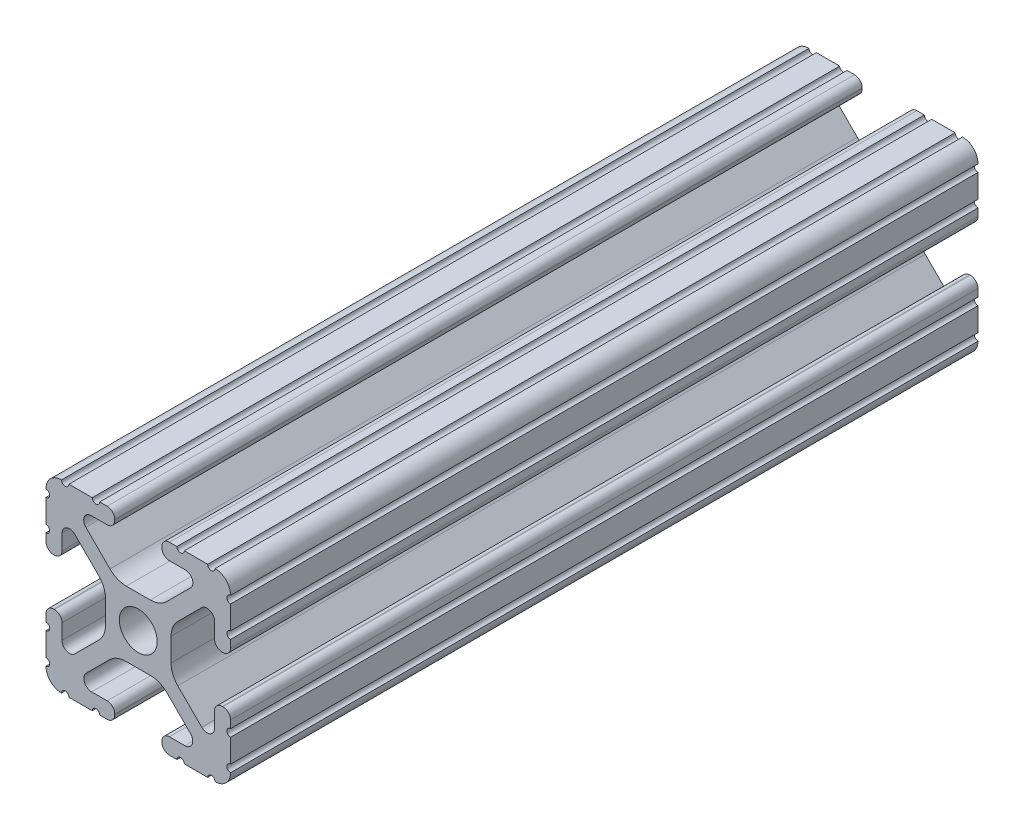
from build123d import *

# Parameters (mm, degrees)
SKETCH1_R      = 2.6035
EXTRUDE1_DEPTH = 102.87


with BuildPart() as part:
    # Sketch1 → Extrude1 (new body)
    with BuildSketch(Plane.XY):
        with BuildLine():
            Line((-1.709253557, -4.4958), (1.709253557, -4.4958))
            ThreePointArc((1.709253557, -4.4958), (2.922935876, -4.736928798), (3.95226937, -5.423689619))
            Line((3.95226937, -5.423689619), (7.179652728, -8.645192207))
            ThreePointArc((7.179652728, -8.645192207), (7.414733441, -9.822812921), (6.41641086, -10.4902))
            Line((6.41641086, -10.4902), (4.28752, -10.4902))
            ThreePointArc((4.28752, -10.4902), (3.545750844, -10.797450844), (3.2385, -11.53922))
            Line((3.2385, -11.53922), (3.2385, -11.65098))
            ThreePointArc((3.2385, -11.65098), (3.545750844, -12.392749156), (4.28752, -12.7))
            Line((4.28752, -12.7), (5.3171344, -12.7))
            ThreePointArc((5.3171344, -12.7), (5.8251344, -12.192), (6.3331344, -12.7))
            Line((6.3331344, -12.7), (9.5504, -12.7))
            ThreePointArc((9.5504, -12.7), (10.058323491, -12.192000006), (10.566399977, -12.699846982))
            ThreePointArc((10.566399977, -12.699846982), (12.082522516, -12.082522516), (12.699846982, -10.566399977))
            ThreePointArc((12.699846982, -10.566399977), (12.192000006, -10.058323491), (12.7, -9.5504))
            Line((12.7, -9.5504), (12.7, -6.3330836))
            ThreePointArc((12.7, -6.3330836), (12.192, -5.8250836), (12.7, -5.3170836))
            Line((12.7, -5.3170836), (12.7, -4.287470133))
            ThreePointArc((12.7, -4.287470133), (12.392749156, -3.545700977), (11.65098, -3.238450133))
            Line((11.65098, -3.238450133), (11.53922, -3.238450133))
            ThreePointArc((11.53922, -3.238450133), (10.797450844, -3.545700977), (10.4902, -4.287470133))
            Line((10.4902, -4.287470133), (10.4902, -6.402089023))
            ThreePointArc((10.4902, -6.402089023), (9.856394933, -7.351113629), (8.736962546, -7.129240479))
            Line((8.736962546, -7.129240479), (5.440484187, -3.838768792))
            ThreePointArc((5.440484187, -3.838768792), (4.75073678, -2.808015636), (4.5085, -1.591658411))
            Line((4.5085, -1.591658411), (4.5085, 1.591658411))
            ThreePointArc((4.5085, 1.591658411), (4.75073678, 2.808015636), (5.440484187, 3.838768792))
            Line((5.440484187, 3.838768792), (8.736962546, 7.129240479))
            ThreePointArc((8.736962546, 7.129240479), (9.856394933, 7.351113629), (10.4902, 6.402089023))
            Line((10.4902, 6.402089023), (10.4902, 4.287470133))
            ThreePointArc((10.4902, 4.287470133), (10.797450844, 3.545700977), (11.53922, 3.238450133))
            Line((11.53922, 3.238450133), (11.65098, 3.238450133))
            ThreePointArc((11.65098, 3.238450133), (12.392749156, 3.545700977), (12.7, 4.287470133))
            Line((12.7, 4.287470133), (12.7, 5.3171344))
            ThreePointArc((12.7, 5.3171344), (12.192, 5.8251344), (12.7, 6.3331344))
            Line((12.7, 6.3331344), (12.7, 9.5504))
            ThreePointArc((12.7, 9.5504), (12.192000006, 10.058323491), (12.699846982, 10.566399977))
            ThreePointArc((12.699846982, 10.566399977), (12.082522516, 12.082522516), (10.566399977, 12.699846982))
            ThreePointArc((10.566399977, 12.699846982), (10.058323491, 12.192000006), (9.5504, 12.7))
            Line((9.5504, 12.7), (6.3330836, 12.7))
            ThreePointArc((6.3330836, 12.7), (5.8250836, 12.192), (5.3170836, 12.7))
            Line((5.3170836, 12.7), (4.2874692, 12.7))
            ThreePointArc((4.2874692, 12.7), (3.545700044, 12.392749156), (3.2384492, 11.65098))
            Line((3.2384492, 11.65098), (3.2384492, 11.53922))
            ThreePointArc((3.2384492, 11.53922), (3.545700044, 10.797450844), (4.2874692, 10.4902))
            Line((4.2874692, 10.4902), (6.476774195, 10.4902))
            ThreePointArc((6.476774195, 10.4902), (7.43216212, 9.851515102), (7.207191475, 8.724540082))
            Line((7.207191475, 8.724540082), (3.900315394, 5.423689619))
            ThreePointArc((3.900315394, 5.423689619), (2.8709819, 4.736928798), (1.657299581, 4.4958))
            Line((1.657299581, 4.4958), (-1.657299581, 4.4958))
            ThreePointArc((-1.657299581, 4.4958), (-2.8709819, 4.736928798), (-3.900315394, 5.423689619))
            Line((-3.900315394, 5.423689619), (-7.207191475, 8.724540082))
            ThreePointArc((-7.207191475, 8.724540082), (-7.43216212, 9.851515102), (-6.476774195, 10.4902))
            Line((-6.476774195, 10.4902), (-4.2874692, 10.4902))
            ThreePointArc((-4.2874692, 10.4902), (-3.545700044, 10.797450844), (-3.2384492, 11.53922))
            Line((-3.2384492, 11.53922), (-3.2384492, 11.65098))
            ThreePointArc((-3.2384492, 11.65098), (-3.545700044, 12.392749156), (-4.2874692, 12.7))
            Line((-4.2874692, 12.7), (-5.3170836, 12.7))
            ThreePointArc((-5.3170836, 12.7), (-5.8250836, 12.192), (-6.3330836, 12.7))
            Line((-6.3330836, 12.7), (-9.5504, 12.7))
            ThreePointArc((-9.5504, 12.7), (-10.058323491, 12.192000006), (-10.566399977, 12.699846982))
            ThreePointArc((-10.566399977, 12.699846982), (-12.082522516, 12.082522516), (-12.699846982, 10.566399977))
            ThreePointArc((-12.699846982, 10.566399977), (-12.192000006, 10.058323491), (-12.7, 9.5504))
            Line((-12.7, 9.5504), (-12.7, 6.3331344))
            ThreePointArc((-12.7, 6.3331344), (-12.192, 5.8251344), (-12.7, 5.3171344))
            Line((-12.7, 5.3171344), (-12.7, 4.287470133))
            ThreePointArc((-12.7, 4.287470133), (-12.392749156, 3.545700977), (-11.65098, 3.238450133))
            Line((-11.65098, 3.238450133), (-11.53922, 3.238450133))
            ThreePointArc((-11.53922, 3.238450133), (-10.797450844, 3.545700977), (-10.4902, 4.287470133))
            Line((-10.4902, 4.287470133), (-10.4902, 6.402089023))
            ThreePointArc((-10.4902, 6.402089023), (-9.856394933, 7.351113629), (-8.736962546, 7.129240479))
            Line((-8.736962546, 7.129240479), (-5.440484187, 3.838768792))
            ThreePointArc((-5.440484187, 3.838768792), (-4.75073678, 2.808015636), (-4.5085, 1.591658411))
            Line((-4.5085, 1.591658411), (-4.5085, -1.591658411))
            ThreePointArc((-4.5085, -1.591658411), (-4.75073678, -2.808015636), (-5.440484187, -3.838768792))
            Line((-5.440484187, -3.838768792), (-8.736962546, -7.129240479))
            ThreePointArc((-8.736962546, -7.129240479), (-9.856394933, -7.351113629), (-10.4902, -6.402089023))
            Line((-10.4902, -6.402089023), (-10.4902, -4.287470133))
            ThreePointArc((-10.4902, -4.287470133), (-10.797450844, -3.545700977), (-11.53922, -3.238450133))
            Line((-11.53922, -3.238450133), (-11.65098, -3.238450133))
            ThreePointArc((-11.65098, -3.238450133), (-12.392749156, -3.545700977), (-12.7, -4.287470133))
            Line((-12.7, -4.287470133), (-12.7, -5.3170836))
            ThreePointArc((-12.7, -5.3170836), (-12.192, -5.8250836), (-12.7, -6.3330836))
            Line((-12.7, -6.3330836), (-12.7, -9.5504))
            ThreePointArc((-12.7, -9.5504), (-12.192000006, -10.058323491), (-12.699846982, -10.566399977))
            ThreePointArc((-12.699846982, -10.566399977), (-12.082522516, -12.082522516), (-10.566399977, -12.699846982))
            ThreePointArc((-10.566399977, -12.699846982), (-10.058323491, -12.192000006), (-9.5504, -12.7))
            Line((-9.5504, -12.7), (-6.3331344, -12.7))
            ThreePointArc((-6.3331344, -12.7), (-5.8251344, -12.192), (-5.3171344, -12.7))
            Line((-5.3171344, -12.7), (-4.28752, -12.7))
            ThreePointArc((-4.28752, -12.7), (-3.545750844, -12.392749156), (-3.2385, -11.65098))
            Line((-3.2385, -11.65098), (-3.2385, -11.53922))
            ThreePointArc((-3.2385, -11.53922), (-3.545750844, -10.797450844), (-4.28752, -10.4902))
            Line((-4.28752, -10.4902), (-6.41641086, -10.4902))
            ThreePointArc((-6.41641086, -10.4902), (-7.414733441, -9.822812921), (-7.179652728, -8.645192207))
            Line((-7.179652728, -8.645192207), (-3.95226937, -5.423689619))
            ThreePointArc((-3.95226937, -5.423689619), (-2.922935876, -4.736928798), (-1.709253557, -4.4958))
        make_face()
        Circle(SKETCH1_R, mode=Mode.SUBTRACT)
    extrude(amount=-EXTRUDE1_DEPTH)


solid = part.part
